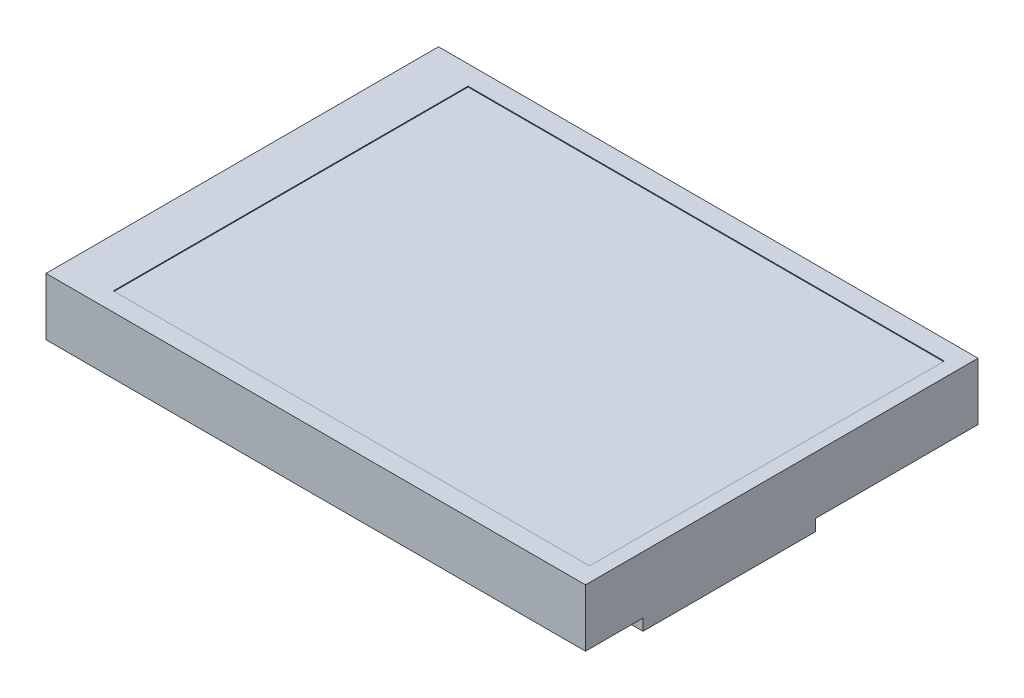
from build123d import *

# Parameters (mm, degrees)
SKETCH1_W           = 65.7
SKETCH1_H           = 47.8
BOSS_EXTRUDE1_DEPTH = 7
SKETCH2_W           = 58
SKETCH2_H           = 43.2
CUT_EXTRUDE1_DEPTH  = 0.1
SKETCH3_W           = 13
SKETCH3_H           = 21
BOSS_EXTRUDE2_DEPTH = 1.4
SKETCH4_W           = 5.5
SKETCH4_H           = 8.5
BOSS_EXTRUDE3_DEPTH = 2.1
SKETCH5_W           = 4
SKETCH5_H           = 15
BOSS_EXTRUDE4_DEPTH = 1.3
SKETCH6_W           = 51
SKETCH6_H           = 5
BOSS_EXTRUDE5_DEPTH = 4


with BuildPart() as part:
    # Sketch1 → Boss-Extrude1 (new body)
    with BuildSketch(Plane(origin=(0, 0, 0), x_dir=(1, 0, 0), z_dir=(0, 1, 0))):
        with Locations((32.85, 23.9)):
            Rectangle(SKETCH1_W, SKETCH1_H)
    extrude(amount=BOSS_EXTRUDE1_DEPTH)

    # Sketch2 → Cut-Extrude1 (cut)
    with BuildSketch(Plane(origin=(0, 7, 0), x_dir=(1, 0, 0), z_dir=(0, 1, 0))):
        with Locations((34.95, 23.85)):
            Rectangle(SKETCH2_W, SKETCH2_H)
    extrude(amount=-CUT_EXTRUDE1_DEPTH, mode=Mode.SUBTRACT)

    # Sketch3 → Boss-Extrude2 (add)
    with BuildSketch(Plane.XZ):
        with Locations((59.2, -17.5)):
            Rectangle(SKETCH3_W, SKETCH3_H)
    extrude(amount=BOSS_EXTRUDE2_DEPTH)

    # Sketch4 → Boss-Extrude3 (add)
    with BuildSketch(Plane.XZ):
        with Locations((27.75, -7.75)):
            Rectangle(SKETCH4_W, SKETCH4_H)
    extrude(amount=BOSS_EXTRUDE3_DEPTH)

    # Sketch5 → Boss-Extrude4 (add)
    with BuildSketch(Plane.XZ):
        with Locations((27.7, -23.5)):
            Rectangle(SKETCH5_W, SKETCH5_H)
    extrude(amount=BOSS_EXTRUDE4_DEPTH)

    # Sketch6 → Boss-Extrude5 (add)
    with BuildSketch(Plane(origin=(0, 0, 0), x_dir=(-1, 0, 0), z_dir=(0, -1, 0))):
        with Locations((-33.2, 43.8)):
            Rectangle(SKETCH6_W, SKETCH6_H)
    extrude(amount=BOSS_EXTRUDE5_DEPTH)


solid = part.part
